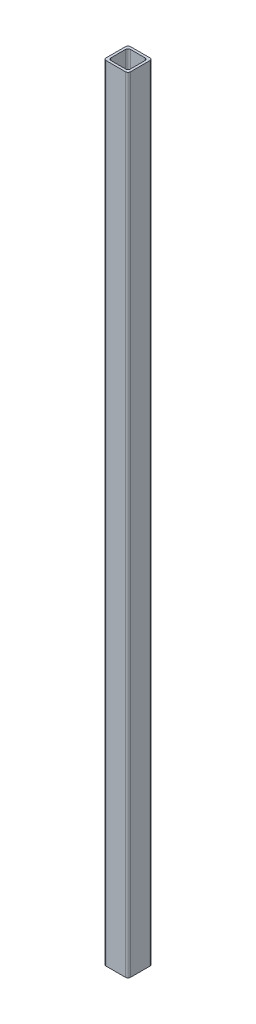
from build123d import *

# Parameters (mm, degrees)
SKETCH1_W           = 10
SKETCH1_H           = 10
BOSS_EXTRUDE1_DEPTH = 310
CUT_EXTRUDE1_DEPTH  = 310
FILLET1_R           = 1
FILLET2_R           = 1
FILLET3_R           = 1
FILLET4_R           = 1
BOSS_EXTRUDE2_DEPTH = 42
CUT_EXTRUDE2_DEPTH  = 35.07
CUT_EXTRUDE3_DEPTH  = 2
BOSS_EXTRUDE4_DEPTH = 370
CUT_EXTRUDE4_DEPTH  = 46.92
SKETCH14_W          = 1
SKETCH14_H          = 46.92
CUT_EXTRUDE5_DEPTH  = 46.92


with BuildPart() as part:
    # Sketch1 → Boss-Extrude1 (new body)
    with BuildSketch(Plane(origin=(0, 0, 0), x_dir=(1, 0, 0), z_dir=(0, 1, 0))):
        with Locations((-3.5625, -0.78125)):
            Rectangle(SKETCH1_W, SKETCH1_H)
    extrude(amount=BOSS_EXTRUDE1_DEPTH)

    # Sketch2 → Cut-Extrude1 (cut)
    with BuildSketch(Plane(origin=(0, 0, 0), x_dir=(-1, 0, 0), z_dir=(0, -1, 0))):
        Polygon((-0.4375, -4.78125), (7.5625, -4.78125), (-0.4375, 3.21875), align=None)
        Polygon((-0.4375, 3.21875), (7.5625, -4.78125), (7.5625, 3.21875), align=None)
    extrude(amount=-CUT_EXTRUDE1_DEPTH, mode=Mode.SUBTRACT)

    # Fillet1
    fillet1_edges = [part.edges().sort_by_distance(p)[0] for p in [
        (0.4375, 155, -3.21875),
        (-8.5625, 155, 5.78125),
        (-8.5625, 155, -4.21875),
        (1.4375, 155, 5.78125),
    ]]
    fillet(fillet1_edges, radius=FILLET1_R)

    # Fillet2
    fillet2_edges = [part.edges().sort_by_distance(p)[0] for p in [
        (-7.5625, 155, 4.78125),
        (1.4375, 155, -4.21875),
    ]]
    fillet(fillet2_edges, radius=FILLET2_R)

    # Fillet3
    fillet3_edges = [part.edges().sort_by_distance(p)[0] for p in [
        (0.4375, 155, 4.78125),
    ]]
    fillet(fillet3_edges, radius=FILLET3_R)

    # Fillet4
    fillet4_edges = [part.edges().sort_by_distance(p)[0] for p in [
        (-7.5625, 155, -3.21875),
    ]]
    fillet(fillet4_edges, radius=FILLET4_R)

    # Sketch3 → Boss-Extrude2 (add)
    with BuildSketch(Plane(origin=(0, 310, 0), x_dir=(1, 0, 0), z_dir=(0, 1, 0))):
        with BuildLine():
            ThreePointArc((0.4375, -5.78125), (1.144606781, -5.488356781), (1.4375, -4.78125))
            Line((1.4375, -4.78125), (1.4375, 3.21875))
            ThreePointArc((1.4375, 3.21875), (1.144606781, 3.925856781), (0.4375, 4.21875))
            Line((0.4375, 4.21875), (-7.5625, 4.21875))
            ThreePointArc((-7.5625, 4.21875), (-8.269606781, 3.925856781), (-8.5625, 3.21875))
            Line((-8.5625, 3.21875), (-8.5625, -4.78125))
            ThreePointArc((-8.5625, -4.78125), (-8.269606781, -5.488356781), (-7.5625, -5.78125))
            Line((-7.5625, -5.78125), (0.4375, -5.78125))
        make_face()
        with BuildLine():
            ThreePointArc((-0.5625, 3.21875), (0.144606781, 2.925856781), (0.4375, 2.21875))
            Line((0.4375, 2.21875), (0.4375, -3.78125))
            ThreePointArc((0.4375, -3.78125), (0.144606781, -4.488356781), (-0.5625, -4.78125))
            Line((-0.5625, -4.78125), (-6.5625, -4.78125))
            ThreePointArc((-6.5625, -4.78125), (-7.269606781, -4.488356781), (-7.5625, -3.78125))
            Line((-7.5625, -3.78125), (-7.5625, 2.21875))
            ThreePointArc((-7.5625, 2.21875), (-7.269606781, 2.925856781), (-6.5625, 3.21875))
            Line((-6.5625, 3.21875), (-0.5625, 3.21875))
        make_face(mode=Mode.SUBTRACT)
    extrude(amount=BOSS_EXTRUDE2_DEPTH)

    # Sketch4 → Cut-Extrude2 (cut)
    with BuildSketch(Plane(origin=(0, 352, 0), x_dir=(1, 0, 0), z_dir=(0, 1, 0))):
        with BuildLine():
            Line((-7.5625, -5.78125), (0.4375, -5.78125))
            ThreePointArc((0.4375, -5.78125), (1.144606781, -5.488356781), (1.4375, -4.78125))
            Line((1.4375, -4.78125), (1.4375, 3.21875))
            ThreePointArc((1.4375, 3.21875), (1.144606781, 3.925856781), (0.4375, 4.21875))
            Line((0.4375, 4.21875), (-7.5625, 4.21875))
            ThreePointArc((-7.5625, 4.21875), (-8.269606781, 3.925856781), (-8.5625, 3.21875))
            Line((-8.5625, 3.21875), (-8.5625, -4.78125))
            ThreePointArc((-8.5625, -4.78125), (-8.269606781, -5.488356781), (-7.5625, -5.78125))
        make_face()
        with BuildLine():
            Line((-6.5625, 3.21875), (-0.5625, 3.21875))
            ThreePointArc((-0.5625, 3.21875), (0.144606781, 2.925856781), (0.4375, 2.21875))
            Line((0.4375, 2.21875), (0.4375, -3.78125))
            ThreePointArc((0.4375, -3.78125), (0.144606781, -4.488356781), (-0.5625, -4.78125))
            Line((-0.5625, -4.78125), (-6.5625, -4.78125))
            ThreePointArc((-6.5625, -4.78125), (-7.269606781, -4.488356781), (-7.5625, -3.78125))
            Line((-7.5625, -3.78125), (-7.5625, 2.21875))
            ThreePointArc((-7.5625, 2.21875), (-7.269606781, 2.925856781), (-6.5625, 3.21875))
        make_face(mode=Mode.SUBTRACT)
    extrude(amount=-CUT_EXTRUDE2_DEPTH, mode=Mode.SUBTRACT)

    # Sketch6 → Cut-Extrude3 (cut)
    with BuildSketch(Plane(origin=(0, 316.93, 0), x_dir=(1, 0, 0), z_dir=(0, 1, 0))):
        with BuildLine():
            Line((-7.5625, -5.78125), (0.4375, -5.78125))
            ThreePointArc((0.4375, -5.78125), (1.144606781, -5.488356781), (1.4375, -4.78125))
            Line((1.4375, -4.78125), (1.4375, 3.21875))
            ThreePointArc((1.4375, 3.21875), (1.144606781, 3.925856781), (0.4375, 4.21875))
            Line((0.4375, 4.21875), (-7.5625, 4.21875))
            ThreePointArc((-7.5625, 4.21875), (-8.269606781, 3.925856781), (-8.5625, 3.21875))
            Line((-8.5625, 3.21875), (-8.5625, -4.78125))
            ThreePointArc((-8.5625, -4.78125), (-8.269606781, -5.488356781), (-7.5625, -5.78125))
        make_face()
    extrude(amount=-CUT_EXTRUDE3_DEPTH, mode=Mode.SUBTRACT)

    # Sketch7 → Boss-Extrude4 (add)
    with BuildSketch(Plane(origin=(0, 314.93, 0), x_dir=(1, 0, 0), z_dir=(0, 1, 0))):
        with BuildLine():
            Line((-8.5625, 3.21875), (-8.5625, -4.78125))
            ThreePointArc((-8.5625, -4.78125), (-8.269606781, -5.488356781), (-7.5625, -5.78125))
            Line((-7.5625, -5.78125), (0.4375, -5.78125))
            ThreePointArc((0.4375, -5.78125), (1.144606781, -5.488356781), (1.4375, -4.78125))
            Line((1.4375, -4.78125), (1.4375, 3.21875))
            ThreePointArc((1.4375, 3.21875), (1.144606781, 3.925856781), (0.4375, 4.21875))
            Line((0.4375, 4.21875), (-7.5625, 4.21875))
            ThreePointArc((-7.5625, 4.21875), (-8.269606781, 3.925856781), (-8.5625, 3.21875))
        make_face()
        with BuildLine():
            Line((-6.5625, 3.21875), (-0.5625, 3.21875))
            ThreePointArc((-0.5625, 3.21875), (0.144606781, 2.925856781), (0.4375, 2.21875))
            Line((0.4375, 2.21875), (0.4375, -3.78125))
            ThreePointArc((0.4375, -3.78125), (0.144606781, -4.488356781), (-0.5625, -4.78125))
            Line((-0.5625, -4.78125), (-6.5625, -4.78125))
            ThreePointArc((-6.5625, -4.78125), (-7.269606781, -4.488356781), (-7.5625, -3.78125))
            Line((-7.5625, -3.78125), (-7.5625, 2.21875))
            ThreePointArc((-7.5625, 2.21875), (-7.269606781, 2.925856781), (-6.5625, 3.21875))
        make_face(mode=Mode.SUBTRACT)
    extrude(amount=-BOSS_EXTRUDE4_DEPTH)

    # Sketch13 → Cut-Extrude4 (cut)
    with BuildSketch(Plane(origin=(0, -55.07, 0), x_dir=(-1, 0, 0), z_dir=(0, -1, 0))):
        with BuildLine():
            Line((6.7625, -4.78125), (7.5625, -5.78125))
            ThreePointArc((7.5625, -5.78125), (8.269606781, -5.488356781), (8.5625, -4.78125))
            Line((8.5625, -4.78125), (8.5625, 3.21875))
            ThreePointArc((8.5625, 3.21875), (8.269606781, 3.925856781), (7.5625, 4.21875))
            Line((7.5625, 4.21875), (3.5625, 4.21875))
            Line((3.5625, 4.21875), (3.5625, 3.21875))
            Line((3.5625, 3.21875), (6.5625, 3.21875))
            Line((6.5625, 3.21875), (7.5625, 3.21875))
            Line((7.5625, 3.21875), (7.5625, 2.21875))
            Line((7.5625, 2.21875), (7.5625, -3.78125))
            Line((7.5625, -3.78125), (7.5625, -4.78125))
            Line((7.5625, -4.78125), (6.7625, -4.78125))
        make_face()
        with BuildLine():
            Line((-0.4375, -5.78125), (7.5625, -5.78125))
            Line((7.5625, -5.78125), (6.7625, -4.78125))
            Line((6.7625, -4.78125), (6.5625, -4.78125))
            Line((6.5625, -4.78125), (0.5625, -4.78125))
            Line((0.5625, -4.78125), (-0.4375, -4.78125))
            Line((-0.4375, -4.78125), (-0.4375, -3.78125))
            Line((-0.4375, -3.78125), (-0.4375, 2.21875))
            Line((-0.4375, 2.21875), (-0.4375, 3.21875))
            Line((-0.4375, 3.21875), (0.3625, 3.21875))
            Line((0.3625, 3.21875), (-0.4375, 4.21875))
            ThreePointArc((-0.4375, 4.21875), (-1.144606781, 3.925856781), (-1.4375, 3.21875))
            Line((-1.4375, 3.21875), (-1.4375, -4.78125))
            ThreePointArc((-1.4375, -4.78125), (-1.144606781, -5.488356781), (-0.4375, -5.78125))
        make_face()
        Polygon((-0.4375, 4.21875), (0.3625, 3.21875), (0.5625, 3.21875), (3.5625, 3.21875), (3.5625, 4.21875), align=None)
    extrude(amount=-CUT_EXTRUDE4_DEPTH, mode=Mode.SUBTRACT)

    # Sketch14 → Cut-Extrude5 (cut)
    with BuildSketch(Plane(origin=(0.4375, 0, 0), x_dir=(0, 0, -1), z_dir=(1, 0, 0))):
        with Locations((-4.28125, -31.61)):
            Rectangle(SKETCH14_W, SKETCH14_H)
        with Locations((2.71875, -31.61)):
            Rectangle(SKETCH14_W, SKETCH14_H)
    extrude(amount=-CUT_EXTRUDE5_DEPTH, mode=Mode.SUBTRACT)


solid = part.part
